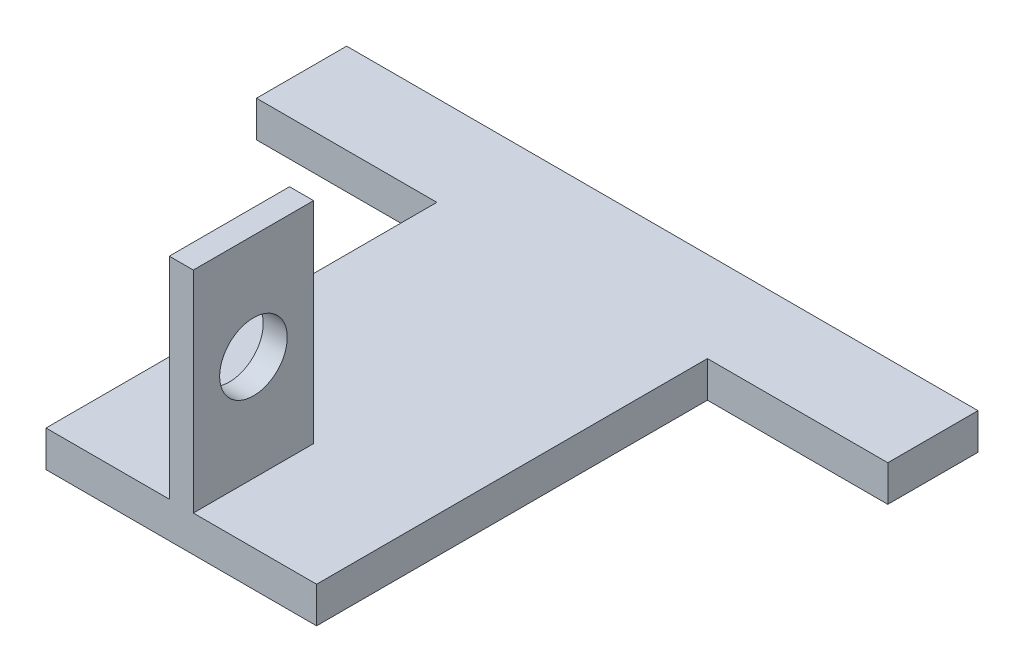
from build123d import *

# Parameters (mm, degrees)
SKETCH1_W           = 18
SKETCH1_H           = 32
SKETCH1_W_2         = 12
SKETCH1_H_2         = 6
BOSS_EXTRUDE1_DEPTH = 2.4
SKETCH4_W           = 1.6
SKETCH4_H           = 8
BOSS_EXTRUDE3_DEPTH = 14
CUT_EXTRUDE2_REACH  = 23.8
SKETCH5_R           = 2.25


with BuildPart() as part:
    # Sketch1 → Boss-Extrude1 (new body)
    with BuildSketch(Plane(origin=(0, 0, 0), x_dir=(1, 0, 0), z_dir=(0, 1, 0))):
        Rectangle(SKETCH1_W, SKETCH1_H)
        with Locations((-15, 13)):
            Rectangle(SKETCH1_W_2, SKETCH1_H_2)
        with Locations((15, 13)):
            Rectangle(SKETCH1_W_2, SKETCH1_H_2)
    extrude(amount=BOSS_EXTRUDE1_DEPTH)

    # Sketch4 → Boss-Extrude3 (add)
    with BuildSketch(Plane(origin=(0, 2.4, 0), x_dir=(1, 0, 0), z_dir=(0, 1, 0))):
        with Locations((0, -12)):
            Rectangle(SKETCH4_W, SKETCH4_H)
    extrude(amount=BOSS_EXTRUDE3_DEPTH)

    # Sketch5 → Cut-Extrude2 (cut, up to next)
    with BuildSketch(Plane.ZY.offset(0.8), mode=Mode.PRIVATE) as cut_extrude2_sk1:
        with Locations((12, 9.4)):
            Circle(SKETCH5_R)
    cut_extrude2_tool1 = extrude(cut_extrude2_sk1.sketch, amount=-CUT_EXTRUDE2_REACH, mode=Mode.PRIVATE) & part.part
    add(cut_extrude2_tool1.solids().sort_by_distance((-0.8, 9.4, 12))[0], mode=Mode.SUBTRACT)


solid = part.part
